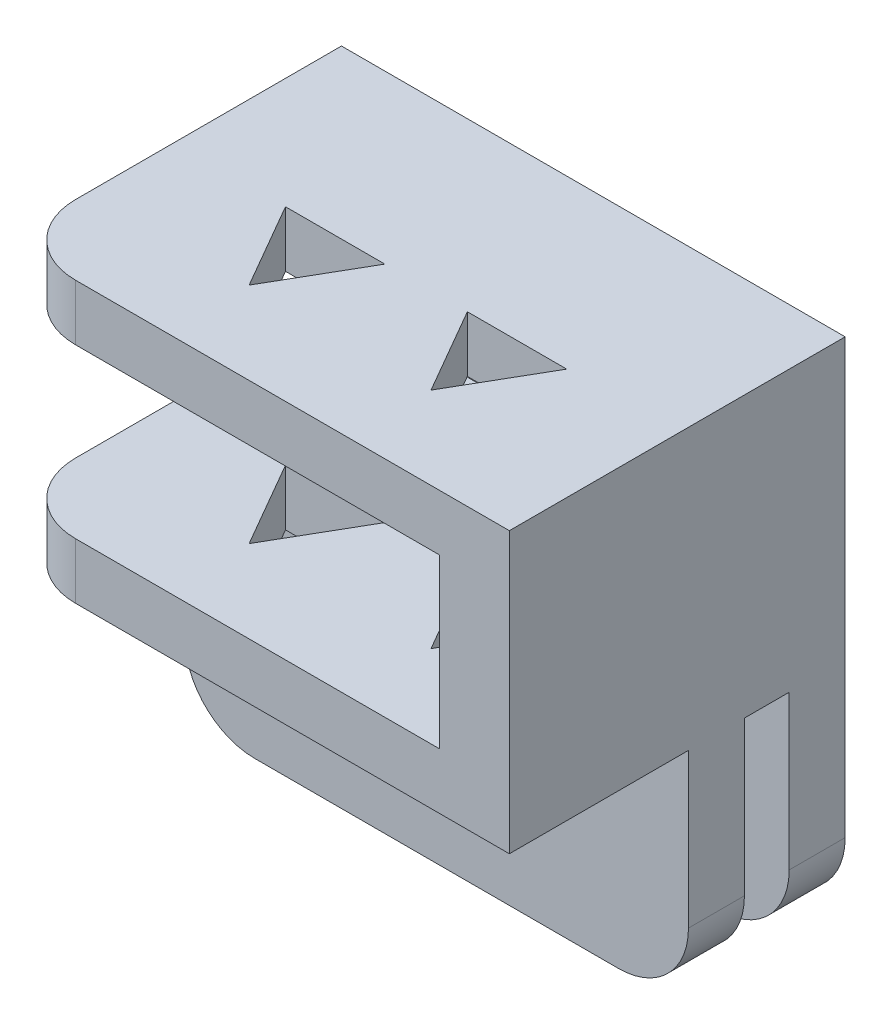
from build123d import *

# Parameters (mm, degrees)
BOSS_EXTRUDE1_DEPTH = 9
CUT_EXTRUDE1_DEPTH  = 13
CUT_EXTRUDE2_DEPTH  = 19
FILLET1_R           = 2.5


with BuildPart() as part:
    # Sketch1 → Boss-Extrude1 (new body, symmetric)
    with BuildSketch(Plane(origin=(0, 0, 0), x_dir=(0, 0, -1), z_dir=(1, 0, 0))):
        Polygon((6, -5), (6, -13), (4, -13), (4, -5), (2.4, -5), (2.4, -13), (0.4, -13), (0.4, -5), (-6, -5), (-6, 5), (6, 5), align=None)
    extrude(amount=BOSS_EXTRUDE1_DEPTH, both=True)

    # Sketch2 → Cut-Extrude1 (cut, through all)
    with BuildSketch(Plane.XY.offset(6)):
        Polygon((-6.5, 3), (-9, 3), (-9, -3), (-6.5, -3), (6.5, -3), (6.5, 3), align=None)
    extrude(amount=-CUT_EXTRUDE1_DEPTH, mode=Mode.SUBTRACT)

    # Sketch4 → Cut-Extrude2 (cut, through all)
    with BuildSketch(Plane(origin=(0, 5, 0), x_dir=(1, 0, 0), z_dir=(0, 1, 0))):
        Polygon((3.25, -3.05), (5.025352078, 0.025), (1.474647922, 0.025), align=None)
        Polygon((-1.474647922, 0.025), (-5.025352078, 0.025), (-3.25, -3.05), align=None)
    extrude(amount=-CUT_EXTRUDE2_DEPTH, mode=Mode.SUBTRACT)

    # Fillet1
    fillet1_edges = [part.edges().sort_by_distance(p)[0] for p in [
        (-9, -13, -5),
        (-9, -13, -1.4),
        (-9, 4, 6),
        (9, -13, -1.4),
        (9, -13, -5),
        (-9, -4, 6),
    ]]
    fillet(fillet1_edges, radius=FILLET1_R)


solid = part.part
